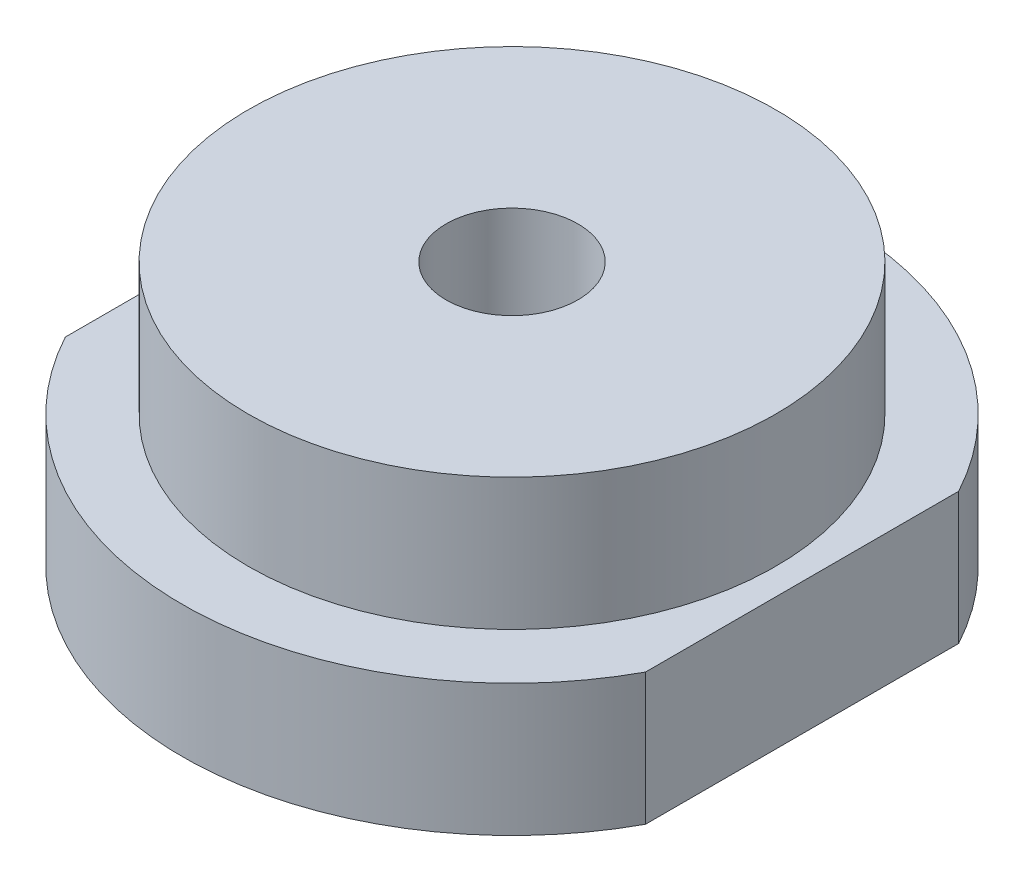
from build123d import *

# Parameters (mm, degrees)
SKIZZE1_R                       = 12.5
AUFSATZ_LINEAR_AUSTRAGEN1_DEPTH = 5
SKIZZE2_R                       = 10
AUFSATZ_LINEAR_AUSTRAGEN2_DEPTH = 5
SKIZZE3_R                       = 2.5
SCHNITT_LINEAR_AUSTRAGEN1_DEPTH = 11


with BuildPart() as part:
    # Skizze1 → Aufsatz-Linear austragen1 (new body)
    with BuildSketch(Plane(origin=(0, 0, 0), x_dir=(1, 0, 0), z_dir=(0, 1, 0))):
        Circle(SKIZZE1_R)
    extrude(amount=AUFSATZ_LINEAR_AUSTRAGEN1_DEPTH)

    # Skizze2 → Aufsatz-Linear austragen2 (add)
    with BuildSketch(Plane(origin=(0, 5, 0), x_dir=(1, 0, 0), z_dir=(0, 1, 0))):
        Circle(SKIZZE2_R)
    extrude(amount=AUFSATZ_LINEAR_AUSTRAGEN2_DEPTH)

    # Skizze3 → Schnitt-Linear austragen1 (cut, through all)
    with BuildSketch(Plane(origin=(0, 10, 0), x_dir=(1, 0, 0), z_dir=(0, 1, 0))):
        Circle(SKIZZE3_R)
        with BuildLine():
            Line((-11, 5.937171044), (-11, -5.937171044))
            ThreePointArc((-11, -5.937171044), (-12.5, 0), (-11, 5.937171044))
        make_face()
        with BuildLine():
            Line((11, 5.937171044), (11, -5.937171044))
            ThreePointArc((11, -5.937171044), (12.5, 0), (11, 5.937171044))
        make_face()
    extrude(amount=-SCHNITT_LINEAR_AUSTRAGEN1_DEPTH, mode=Mode.SUBTRACT)


solid = part.part
